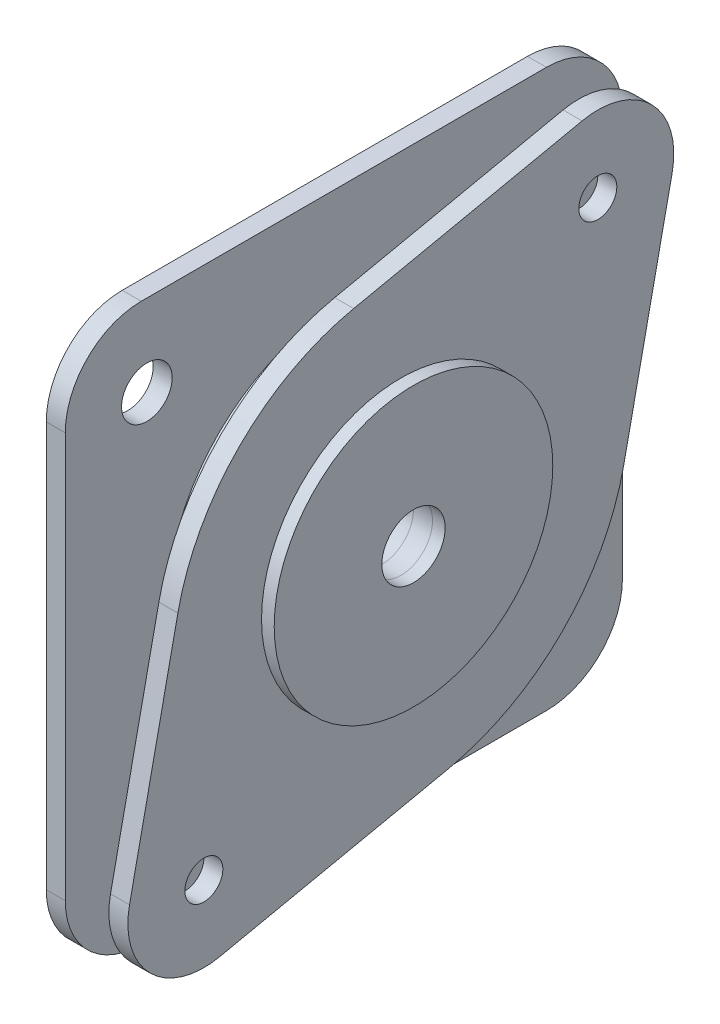
from build123d import *

# Parameters (mm, degrees)
SKETCH1_R           = 2.5
BOSS_EXTRUDE1_DEPTH = 1.5
SKETCH2_R           = 14
SKETCH2_R_2         = 2.5
BOSS_EXTRUDE2_DEPTH = 3
SKETCH4_R           = 1.5
SKETCH4_R_2         = 2.502
BOSS_EXTRUDE3_DEPTH = 1.5
SKETCH3_R           = 2
CUT_EXTRUDE1_DEPTH  = 7.5
SKETCH5_R           = 11
SKETCH5_R_2         = 2.5
BOSS_EXTRUDE4_DEPTH = 1


with BuildPart() as part:
    # Sketch1 → Boss-Extrude1 (new body)
    with BuildSketch(Plane(origin=(0, 0, 0), x_dir=(0, 0, -1), z_dir=(1, 0, 0))):
        with BuildLine():
            Line((-16, 22), (16, 22))
            ThreePointArc((16, 22), (20.242640687, 20.242640687), (22, 16))
            Line((22, 16), (22, -16))
            ThreePointArc((22, -16), (20.242640687, -20.242640687), (16, -22))
            Line((16, -22), (-16, -22))
            ThreePointArc((-16, -22), (-20.242640687, -20.242640687), (-22, -16))
            Line((-22, -16), (-22, 16))
            ThreePointArc((-22, 16), (-20.242640687, 20.242640687), (-16, 22))
        make_face()
        Circle(SKETCH1_R, mode=Mode.SUBTRACT)
    extrude(amount=BOSS_EXTRUDE1_DEPTH)

    # Sketch2 → Boss-Extrude2 (add)
    with BuildSketch(Plane(origin=(1.5, 0, 0), x_dir=(0, 0, -1), z_dir=(1, 0, 0))):
        Circle(SKETCH2_R)
        Circle(SKETCH2_R_2, mode=Mode.SUBTRACT)
    extrude(amount=BOSS_EXTRUDE2_DEPTH)

    # Sketch4 → Boss-Extrude3 (add)
    with BuildSketch(Plane(origin=(4.5, 0, 0), x_dir=(0, 0, -1), z_dir=(1, 0, 0))):
        with BuildLine():
            Line((-3.723678165, 17.610205059), (14.314456464, 21.426417539))
            ThreePointArc((14.314456464, 21.426417539), (19.79871712, 19.799262609), (21.426577165, 14.315211208))
            Line((21.426577165, 14.315211208), (17.612683935, -3.723413935))
            ThreePointArc((17.612683935, -3.723413935), (12.730477998, -12.7273661), (3.726952372, -17.610358594))
            Line((3.726952372, -17.610358594), (-14.314460707, -21.426487839))
            ThreePointArc((-14.314460707, -21.426487839), (-19.798989873, -19.798771294), (-21.426091866, -14.314059778))
            Line((-21.426091866, -14.314059778), (-17.607941103, 3.726925591))
            ThreePointArc((-17.607941103, 3.726925591), (-12.725471256, 12.728372851), (-3.723678165, 17.610205059))
        make_face()
        with Locations((15.556349186, 15.556349186)):
            Circle(SKETCH4_R, mode=Mode.SUBTRACT)
        with Locations((-15.554349186, -15.556349186)):
            Circle(SKETCH4_R, mode=Mode.SUBTRACT)
        with Locations(Location((0.002, 0, 0), (0, 0, 180))):
            Circle(SKETCH4_R_2, mode=Mode.SUBTRACT)
    extrude(amount=BOSS_EXTRUDE3_DEPTH)

    # Sketch3 → Cut-Extrude1 (cut)
    with BuildSketch(Plane(origin=(4.5, 0, 0), x_dir=(0, 0, -1), z_dir=(1, 0, 0))):
        with Locations((15.556349186, 15.556349186)):
            Circle(SKETCH3_R)
        with Locations((15.556349186, -15.556349186)):
            Circle(SKETCH3_R)
        with Locations((-15.556349186, -15.556349186)):
            Circle(SKETCH3_R)
        with Locations((-15.556349186, 15.556349186)):
            Circle(SKETCH3_R)
    extrude(amount=-CUT_EXTRUDE1_DEPTH, mode=Mode.SUBTRACT)

    # Sketch5 → Boss-Extrude4 (add)
    with BuildSketch(Plane(origin=(6, 0, 0), x_dir=(0, 0, -1), z_dir=(1, 0, 0))):
        Circle(SKETCH5_R)
        with Locations(Location((0, 0, 0), (0, 0, 180))):
            Circle(SKETCH5_R_2, mode=Mode.SUBTRACT)
    extrude(amount=BOSS_EXTRUDE4_DEPTH)


solid = part.part
